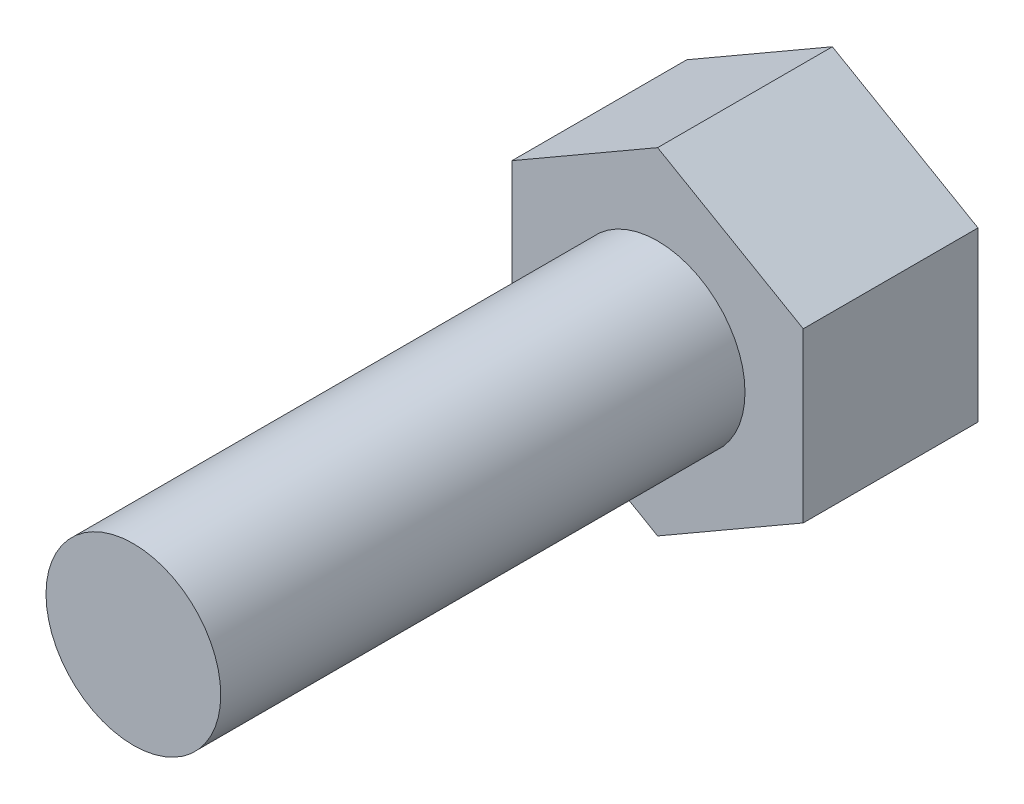
from build123d import *

# Parameters (mm, degrees)
SKETCH1_R           = 1.5
BOSS_EXTRUDE1_DEPTH = 9
BOSS_EXTRUDE2_DEPTH = 3


with BuildPart() as part:
    # Sketch1 → Boss-Extrude1 (new body)
    with BuildSketch(Plane.XY):
        with Locations((-63.49476159, 14.978708134)):
            Circle(SKETCH1_R)
    extrude(amount=BOSS_EXTRUDE1_DEPTH)

    # Sketch2 → Boss-Extrude2 (add)
    with BuildSketch(Plane(origin=(0, 0, 0), x_dir=(-1, 0, 0), z_dir=(0, 0, -1))):
        Polygon((63.49476159, 12.091956788), (65.99476159, 13.535332461), (65.99476159, 16.422083807), (63.49476159, 17.86545948), (60.99476159, 16.422083807), (60.99476159, 13.535332461), align=None)
    extrude(amount=BOSS_EXTRUDE2_DEPTH)


solid = part.part
